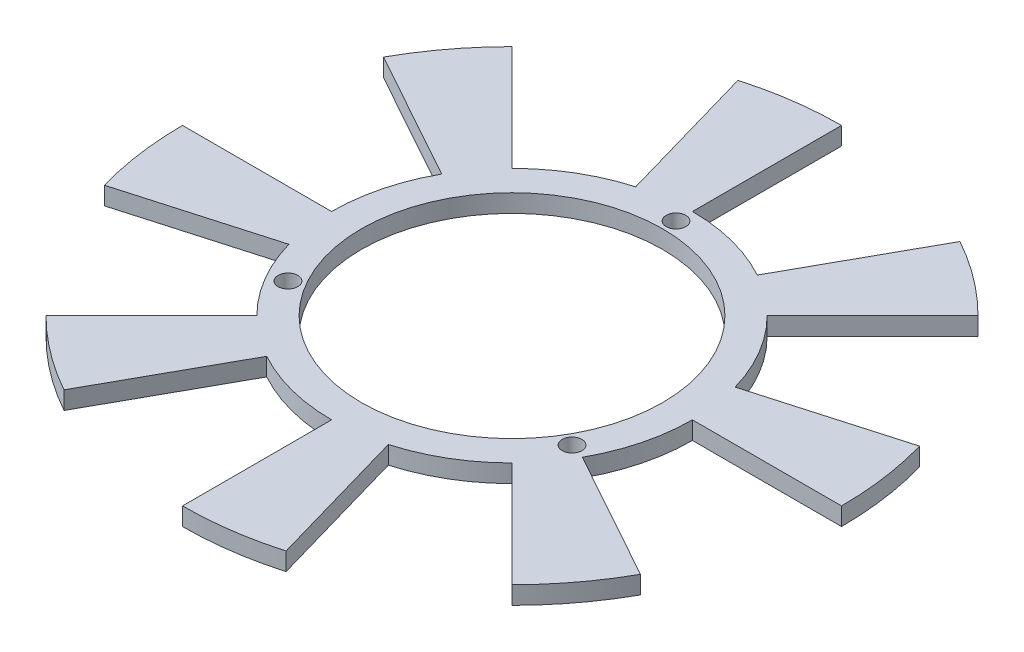
from build123d import *

# Parameters (mm, degrees)
SKETCH1_R           = 30.25
SKETCH1_R_2         = 25.25
EXTRUDE_THIN1_DEPTH = 3
SKETCH2_R           = 1.65
CUT_EXTRUDE3_DEPTH  = 10
BOSS_EXTRUDE1_DEPTH = 3


with BuildPart() as part:
    # Sketch1 → Extrude-Thin1 (new body)
    with BuildSketch(Plane(origin=(0, 0, 0), x_dir=(1, 0, 0), z_dir=(0, 1, 0))):
        Circle(SKETCH1_R)
        Circle(SKETCH1_R_2, mode=Mode.SUBTRACT)
    extrude(amount=-EXTRUDE_THIN1_DEPTH)

    # Sketch2 → Cut-Extrude3 (cut)
    with BuildSketch(Plane(origin=(0, 0, 0), x_dir=(1, 0, 0), z_dir=(0, 1, 0))):
        with Locations((0, 27.5)):
            Circle(SKETCH2_R)
        with Locations((23.815698604, -13.75)):
            Circle(SKETCH2_R)
        with Locations((-23.815698604, -13.75)):
            Circle(SKETCH2_R)
    extrude(amount=-CUT_EXTRUDE3_DEPTH, mode=Mode.SUBTRACT)

    # Sketch5 → Boss-Extrude1 (add)
    with BuildSketch(Plane.XZ.offset(3)):
        with BuildLine():
            Line((0, 55.25), (0, 30.25))
            ThreePointArc((0, 30.25), (4.209986304, 29.955609079), (8.338030013, 29.078166302))
            Line((8.338030013, 29.078166302), (15.228963909, 53.109708701))
            ThreePointArc((15.228963909, 53.109708701), (7.689313828, 54.712310798), (0, 55.25))
        make_face()
        with BuildLine():
            Line((39.067649661, 39.067649661), (21.389980131, 21.389980131))
            ThreePointArc((21.389980131, 21.389980131), (24.158724179, 18.20490445), (26.457246141, 14.665491012))
            Line((26.457246141, 14.665491012), (48.322738819, 26.785731519))
            ThreePointArc((48.322738819, 26.785731519), (44.12461193, 33.250280029), (39.067649661, 39.067649661))
        make_face()
        with BuildLine():
            Line((55.25, 0), (30.25, 0))
            ThreePointArc((30.25, 0), (29.955609079, -4.209986304), (29.078166302, -8.338030013))
            Line((29.078166302, -8.338030013), (53.109708701, -15.228963909))
            ThreePointArc((53.109708701, -15.228963909), (54.712310798, -7.689313828), (55.25, 0))
        make_face()
        with BuildLine():
            Line((39.067649661, -39.067649661), (21.389980131, -21.389980131))
            ThreePointArc((21.389980131, -21.389980131), (18.20490445, -24.158724179), (14.665491012, -26.457246141))
            Line((14.665491012, -26.457246141), (26.785731519, -48.322738819))
            ThreePointArc((26.785731519, -48.322738819), (33.250280029, -44.12461193), (39.067649661, -39.067649661))
        make_face()
        with BuildLine():
            Line((0, -55.25), (0, -30.25))
            ThreePointArc((0, -30.25), (-4.209986304, -29.955609079), (-8.338030013, -29.078166302))
            Line((-8.338030013, -29.078166302), (-15.228963909, -53.109708701))
            ThreePointArc((-15.228963909, -53.109708701), (-7.689313828, -54.712310798), (0, -55.25))
        make_face()
        with BuildLine():
            Line((-39.067649661, -39.067649661), (-21.389980131, -21.389980131))
            ThreePointArc((-21.389980131, -21.389980131), (-24.158724179, -18.20490445), (-26.457246141, -14.665491012))
            Line((-26.457246141, -14.665491012), (-48.322738819, -26.785731519))
            ThreePointArc((-48.322738819, -26.785731519), (-44.12461193, -33.250280029), (-39.067649661, -39.067649661))
        make_face()
        with BuildLine():
            Line((-55.25, 0), (-30.25, 0))
            ThreePointArc((-30.25, 0), (-29.955609079, 4.209986304), (-29.078166302, 8.338030013))
            Line((-29.078166302, 8.338030013), (-53.109708701, 15.228963909))
            ThreePointArc((-53.109708701, 15.228963909), (-54.712310798, 7.689313828), (-55.25, 0))
        make_face()
        with BuildLine():
            Line((-39.067649661, 39.067649661), (-21.389980131, 21.389980131))
            ThreePointArc((-21.389980131, 21.389980131), (-18.20490445, 24.158724179), (-14.665491012, 26.457246141))
            Line((-14.665491012, 26.457246141), (-26.785731519, 48.322738819))
            ThreePointArc((-26.785731519, 48.322738819), (-33.250280029, 44.12461193), (-39.067649661, 39.067649661))
        make_face()
    extrude(amount=-BOSS_EXTRUDE1_DEPTH)


solid = part.part
